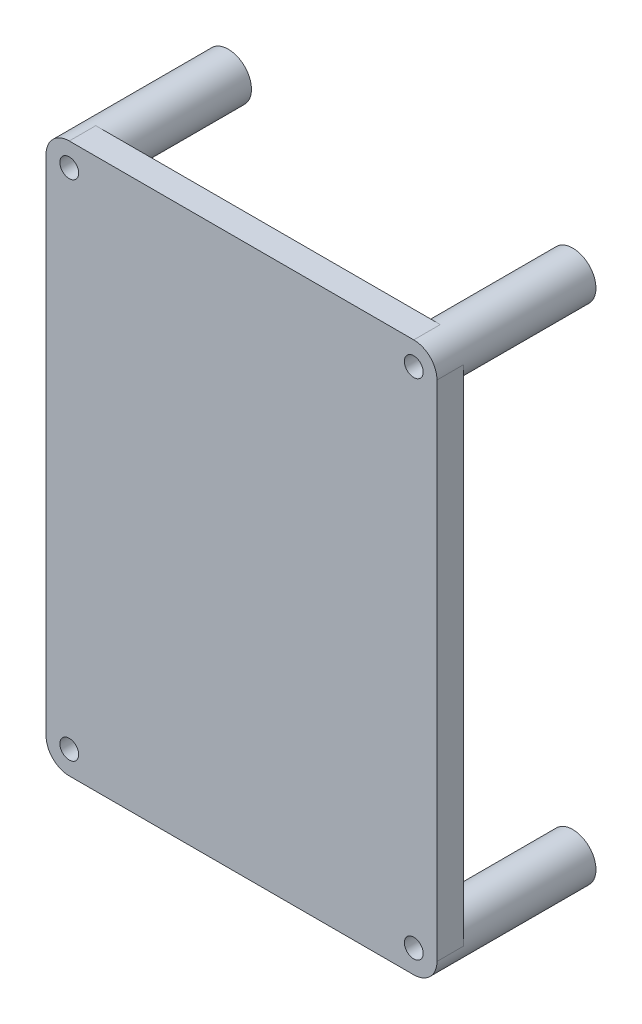
from build123d import *

# Parameters (mm, degrees)
SKETCH1_R           = 1.4224
BOSS_EXTRUDE1_DEPTH = 4
SKETCH3_R           = 3.5
SKETCH3_R_2         = 1.4224
BOSS_EXTRUDE2_DEPTH = 20


with BuildPart() as part:
    # Sketch1 → Boss-Extrude1 (new body)
    with BuildSketch(Plane.XY.offset(206.266714263)):
        with BuildLine():
            Line((164.026557277, 113.230165261), (164.026557277, 189.230165261))
            ThreePointArc((164.026557277, 189.230165261), (163.001431011, 191.705038995), (160.526557277, 192.730165261))
            Line((160.526557277, 192.730165261), (108.526557277, 192.730165261))
            ThreePointArc((108.526557277, 192.730165261), (106.051683543, 191.705038995), (105.026557277, 189.230165261))
            Line((105.026557277, 189.230165261), (105.026557277, 113.230165261))
            ThreePointArc((105.026557277, 113.230165261), (106.051683543, 110.755291526), (108.526557277, 109.730165261))
            Line((108.526557277, 109.730165261), (160.526557277, 109.730165261))
            ThreePointArc((160.526557277, 109.730165261), (163.001431011, 110.755291526), (164.026557277, 113.230165261))
        make_face()
        with Locations((160.526557277, 113.230165261)):
            Circle(SKETCH1_R, mode=Mode.SUBTRACT)
        with Locations((108.526557277, 113.230165261)):
            Circle(SKETCH1_R, mode=Mode.SUBTRACT)
        with Locations((160.526557277, 189.230165261)):
            Circle(SKETCH1_R, mode=Mode.SUBTRACT)
        with Locations((108.526557277, 189.230165261)):
            Circle(SKETCH1_R, mode=Mode.SUBTRACT)
    extrude(amount=BOSS_EXTRUDE1_DEPTH)

    # Sketch3 → Boss-Extrude2 (add)
    with BuildSketch(Plane(origin=(0, 0, 206.266714263), x_dir=(-1, 0, 0), z_dir=(0, 0, -1))):
        with Locations((-108.526557277, 189.230165261)):
            Circle(SKETCH3_R)
        with Locations((-108.526557277, 189.230165261)):
            Circle(SKETCH3_R_2, mode=Mode.SUBTRACT)
        with Locations((-160.526557277, 189.230165261)):
            Circle(SKETCH3_R)
        with Locations((-160.526557277, 189.230165261)):
            Circle(SKETCH3_R_2, mode=Mode.SUBTRACT)
        with Locations((-160.526557277, 113.230165261)):
            Circle(SKETCH3_R)
        with Locations((-160.526557277, 113.230165261)):
            Circle(SKETCH3_R_2, mode=Mode.SUBTRACT)
        with Locations((-108.526557277, 113.230165261)):
            Circle(SKETCH3_R)
        with Locations((-108.526557277, 113.230165261)):
            Circle(SKETCH3_R_2, mode=Mode.SUBTRACT)
    extrude(amount=BOSS_EXTRUDE2_DEPTH)


solid = part.part
